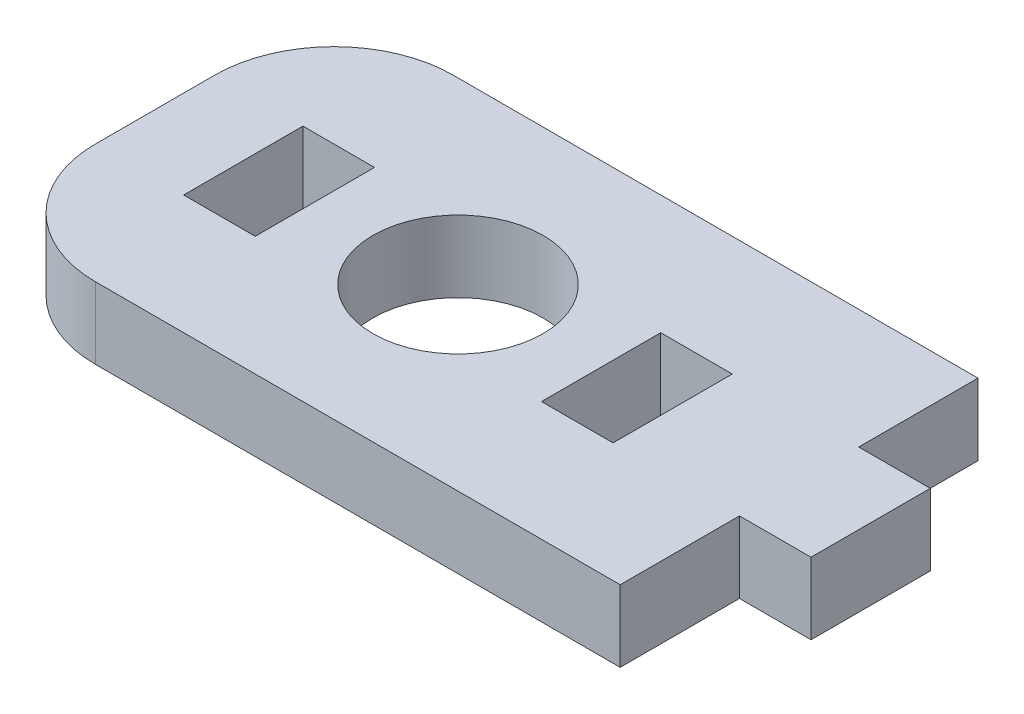
from build123d import *

# Parameters (mm, degrees)
SKETCH1_R           = 3.5685
SKETCH1_W           = 3
SKETCH1_H           = 5
BOSS_EXTRUDE1_DEPTH = 3
FILLET1_R           = 5


with BuildPart() as part:
    # Sketch1 → Boss-Extrude1 (new body)
    with BuildSketch(Plane(origin=(0, 0, 0), x_dir=(1, 0, 0), z_dir=(0, 1, 0))):
        Polygon((-21.821592901, -5), (-21.821592901, 10), (5.178407099, 10), (5.178407099, 5), (8.178407099, 5), (8.178407099, 0), (5.178407099, 0), (5.178407099, -5), align=None)
        with Locations((-9.121592901, 2.5)):
            Circle(SKETCH1_R, mode=Mode.SUBTRACT)
        with Locations((-16.621592901, 2.5)):
            Rectangle(SKETCH1_W, SKETCH1_H, mode=Mode.SUBTRACT)
        with Locations((-1.621592901, 2.5)):
            Rectangle(SKETCH1_W, SKETCH1_H, mode=Mode.SUBTRACT)
    extrude(amount=BOSS_EXTRUDE1_DEPTH)

    # Fillet1
    fillet1_edges = [part.edges().sort_by_distance(p)[0] for p in [
        (-21.821592901, 1.5, 5),
        (-21.821592901, 1.5, -10),
    ]]
    fillet(fillet1_edges, radius=FILLET1_R)


solid = part.part
